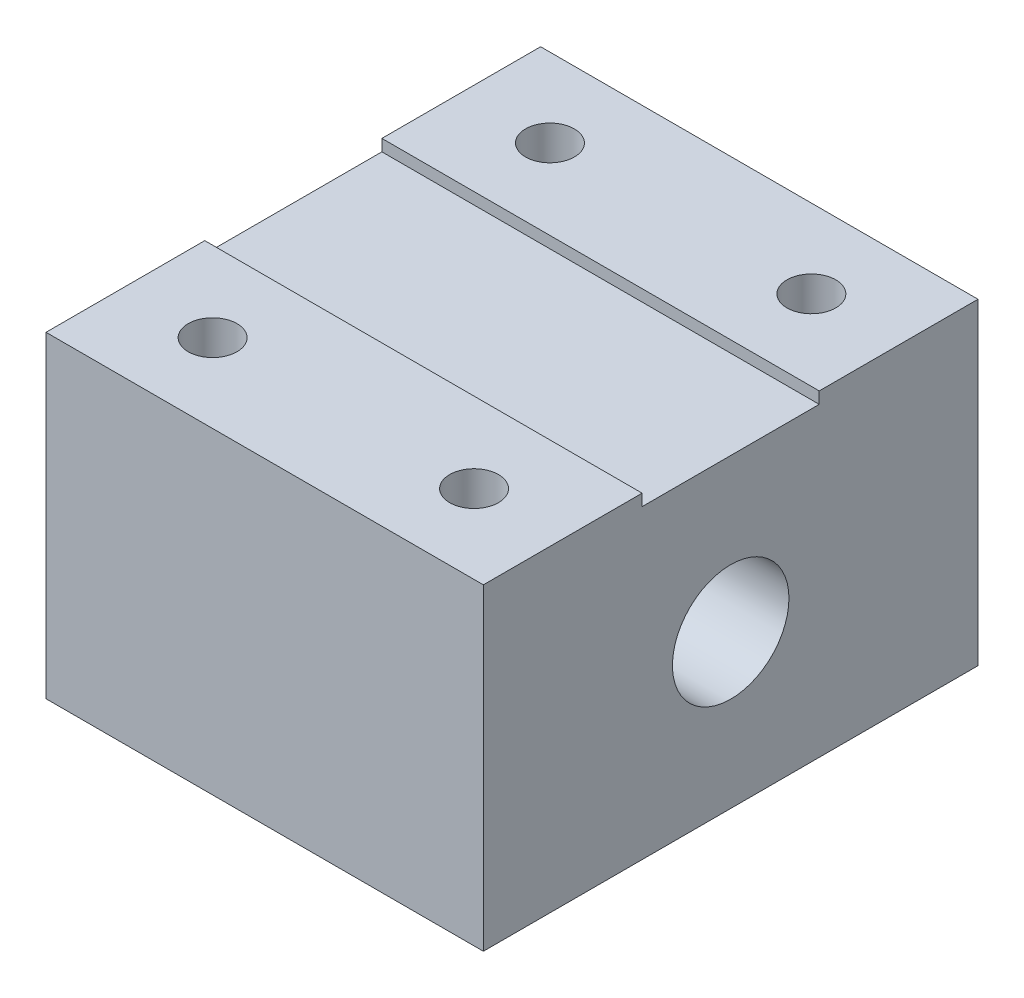
from build123d import *

# Parameters (mm, degrees)
SKETCH1_W           = 30.03
SKETCH1_H           = 33.96
SKETCH1_R           = 1.675
BOSS_EXTRUDE4_DEPTH = 21.79
SKETCH5_R           = 4
CUT_EXTRUDE1_DEPTH  = 31.03
SKETCH7_W           = 30.03
SKETCH7_H           = 12.16
CUT_EXTRUDE2_DEPTH  = 0.8


with BuildPart() as part:
    # Sketch1 → Boss-Extrude4 (new body)
    with BuildSketch(Plane(origin=(0, 0, 0), x_dir=(1, 0, 0), z_dir=(0, 1, 0))):
        with Locations((15.015, 16.98)):
            Rectangle(SKETCH1_W, SKETCH1_H)
        with Locations((23.99, 28.56)):
            Circle(SKETCH1_R, mode=Mode.SUBTRACT)
        with Locations((6.04, 28.56)):
            Circle(SKETCH1_R, mode=Mode.SUBTRACT)
        with Locations((23.99, 5.4)):
            Circle(SKETCH1_R, mode=Mode.SUBTRACT)
        with Locations((6.04, 5.4)):
            Circle(SKETCH1_R, mode=Mode.SUBTRACT)
    extrude(amount=BOSS_EXTRUDE4_DEPTH)

    # Sketch5 → Cut-Extrude1 (cut, through all)
    with BuildSketch(Plane(origin=(30.03, 0, 0), x_dir=(0, 0, -1), z_dir=(1, 0, 0))):
        with Locations((16.98, 10.5)):
            Circle(SKETCH5_R)
    extrude(amount=-CUT_EXTRUDE1_DEPTH, mode=Mode.SUBTRACT)

    # Sketch7 → Cut-Extrude2 (cut)
    with BuildSketch(Plane(origin=(0, 21.79, 0), x_dir=(1, 0, 0), z_dir=(0, 1, 0))):
        with Locations((15.015, 16.98)):
            Rectangle(SKETCH7_W, SKETCH7_H)
    extrude(amount=-CUT_EXTRUDE2_DEPTH, mode=Mode.SUBTRACT)


solid = part.part
